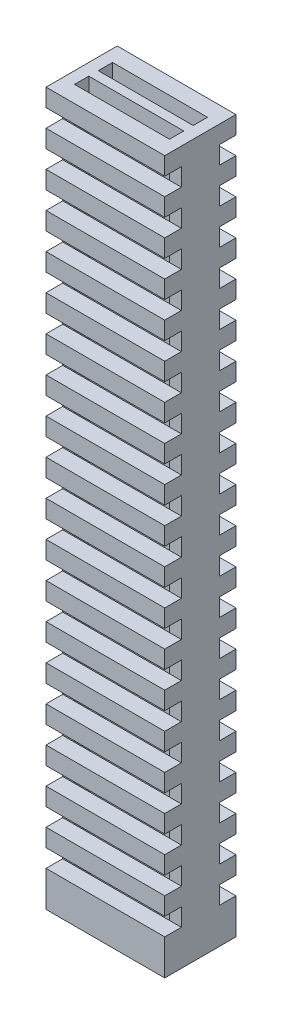
from build123d import *

# Parameters (mm, degrees)
SKETCH1_W                = 5
SKETCH1_H                = 3
BOSS_EXTRUDE1_DEPTH      = 15
CUT_EXTRUDE1_START       = -31
SKETCH2_W                = 4
SKETCH2_H                = 0.6
CUT_EXTRUDE1_DEPTH       = 32
SKETCH3_W                = 5
SKETCH3_H                = 0.75
CUT_EXTRUDE2_DEPTH       = 0.7
LPATTERN1_COUNT          = 19
LPATTERN1_PITCH          = 1.5
MIRROR2_COPY_1_SKETCH_W  = 5
MIRROR2_COPY_1_SKETCH_H  = 0.75
MIRROR2_COPY_1_DEPTH     = 0.7
MIRROR2_COPY_2_SKETCH_W  = 5
MIRROR2_COPY_2_SKETCH_H  = 0.75
MIRROR2_COPY_2_DEPTH     = 0.7
MIRROR2_COPY_3_SKETCH_W  = 5
MIRROR2_COPY_3_SKETCH_H  = 0.75
MIRROR2_COPY_3_DEPTH     = 0.7
MIRROR2_COPY_4_SKETCH_W  = 5
MIRROR2_COPY_4_SKETCH_H  = 0.75
MIRROR2_COPY_4_DEPTH     = 0.7
MIRROR2_COPY_5_SKETCH_W  = 5
MIRROR2_COPY_5_SKETCH_H  = 0.75
MIRROR2_COPY_5_DEPTH     = 0.7
MIRROR2_COPY_6_SKETCH_W  = 5
MIRROR2_COPY_6_SKETCH_H  = 0.75
MIRROR2_COPY_6_DEPTH     = 0.7
MIRROR2_COPY_7_SKETCH_W  = 5
MIRROR2_COPY_7_SKETCH_H  = 0.75
MIRROR2_COPY_7_DEPTH     = 0.7
MIRROR2_COPY_8_SKETCH_W  = 5
MIRROR2_COPY_8_SKETCH_H  = 0.75
MIRROR2_COPY_8_DEPTH     = 0.7
MIRROR2_COPY_9_SKETCH_W  = 5
MIRROR2_COPY_9_SKETCH_H  = 0.75
MIRROR2_COPY_9_DEPTH     = 0.7
MIRROR2_COPY_10_SKETCH_W = 5
MIRROR2_COPY_10_SKETCH_H = 0.75
MIRROR2_COPY_10_DEPTH    = 0.7
MIRROR2_COPY_11_SKETCH_W = 5
MIRROR2_COPY_11_SKETCH_H = 0.75
MIRROR2_COPY_11_DEPTH    = 0.7
MIRROR2_COPY_12_SKETCH_W = 5
MIRROR2_COPY_12_SKETCH_H = 0.75
MIRROR2_COPY_12_DEPTH    = 0.7
MIRROR2_COPY_13_SKETCH_W = 5
MIRROR2_COPY_13_SKETCH_H = 0.75
MIRROR2_COPY_13_DEPTH    = 0.7
MIRROR2_COPY_14_SKETCH_W = 5
MIRROR2_COPY_14_SKETCH_H = 0.75
MIRROR2_COPY_14_DEPTH    = 0.7
MIRROR2_COPY_15_SKETCH_W = 5
MIRROR2_COPY_15_SKETCH_H = 0.75
MIRROR2_COPY_15_DEPTH    = 0.7
MIRROR2_COPY_16_SKETCH_W = 5
MIRROR2_COPY_16_SKETCH_H = 0.75
MIRROR2_COPY_16_DEPTH    = 0.7
MIRROR2_COPY_17_SKETCH_W = 5
MIRROR2_COPY_17_SKETCH_H = 0.75
MIRROR2_COPY_17_DEPTH    = 0.7
MIRROR2_COPY_18_SKETCH_W = 5
MIRROR2_COPY_18_SKETCH_H = 0.75
MIRROR2_COPY_18_DEPTH    = 0.7


with BuildPart() as part:
    # Sketch1 → Boss-Extrude1 (new body, symmetric)
    with BuildSketch(Plane(origin=(0, 0, 0), x_dir=(1, 0, 0), z_dir=(0, 1, 0))):
        Rectangle(SKETCH1_W, SKETCH1_H)
    extrude(amount=BOSS_EXTRUDE1_DEPTH, both=True)

    # Sketch2 → Cut-Extrude1 (cut)
    with BuildSketch(Plane(origin=(0, 15, 0), x_dir=(1, 0, 0), z_dir=(0, 1, 0)).offset(CUT_EXTRUDE1_START)):
        with Locations((0, 0.5)):
            Rectangle(SKETCH2_W, SKETCH2_H)
    cut_extrude1 = extrude(amount=CUT_EXTRUDE1_DEPTH, mode=Mode.SUBTRACT)

    # Mirror1: Cut-Extrude1 across plane
    add(cut_extrude1.mirror(Plane.XY), mode=Mode.SUBTRACT)

    # Sketch3 → Cut-Extrude2 (cut)
    with BuildSketch(Plane.XY.offset(1.5)):
        with Locations((0, 13.875)):
            Rectangle(SKETCH3_W, SKETCH3_H)
    cut_extrude2 = extrude(amount=-CUT_EXTRUDE2_DEPTH, mode=Mode.SUBTRACT)

    # LPattern1: Cut-Extrude2 ×19
    with Locations(*[(0, -i * LPATTERN1_PITCH, 0) for i in range(1, LPATTERN1_COUNT)]):
        add(cut_extrude2, mode=Mode.SUBTRACT)

    # Mirror2: Cut-Extrude2 across plane
    add(cut_extrude2.mirror(Plane.XY), mode=Mode.SUBTRACT)

    # Mirror2 copy 1 sketch → Mirror2 copy 1 (cut)
    with BuildSketch(Plane(origin=(0, -1.5, -1.5), x_dir=(1, 0, 0), z_dir=(0, 0, -1))):
        with Locations((0, -13.875)):
            Rectangle(MIRROR2_COPY_1_SKETCH_W, MIRROR2_COPY_1_SKETCH_H)
    extrude(amount=-MIRROR2_COPY_1_DEPTH, mode=Mode.SUBTRACT)

    # Mirror2 copy 2 sketch → Mirror2 copy 2 (cut)
    with BuildSketch(Plane(origin=(0, -3, -1.5), x_dir=(1, 0, 0), z_dir=(0, 0, -1))):
        with Locations((0, -13.875)):
            Rectangle(MIRROR2_COPY_2_SKETCH_W, MIRROR2_COPY_2_SKETCH_H)
    extrude(amount=-MIRROR2_COPY_2_DEPTH, mode=Mode.SUBTRACT)

    # Mirror2 copy 3 sketch → Mirror2 copy 3 (cut)
    with BuildSketch(Plane(origin=(0, -4.5, -1.5), x_dir=(1, 0, 0), z_dir=(0, 0, -1))):
        with Locations((0, -13.875)):
            Rectangle(MIRROR2_COPY_3_SKETCH_W, MIRROR2_COPY_3_SKETCH_H)
    extrude(amount=-MIRROR2_COPY_3_DEPTH, mode=Mode.SUBTRACT)

    # Mirror2 copy 4 sketch → Mirror2 copy 4 (cut)
    with BuildSketch(Plane(origin=(0, -6, -1.5), x_dir=(1, 0, 0), z_dir=(0, 0, -1))):
        with Locations((0, -13.875)):
            Rectangle(MIRROR2_COPY_4_SKETCH_W, MIRROR2_COPY_4_SKETCH_H)
    extrude(amount=-MIRROR2_COPY_4_DEPTH, mode=Mode.SUBTRACT)

    # Mirror2 copy 5 sketch → Mirror2 copy 5 (cut)
    with BuildSketch(Plane(origin=(0, -7.5, -1.5), x_dir=(1, 0, 0), z_dir=(0, 0, -1))):
        with Locations((0, -13.875)):
            Rectangle(MIRROR2_COPY_5_SKETCH_W, MIRROR2_COPY_5_SKETCH_H)
    extrude(amount=-MIRROR2_COPY_5_DEPTH, mode=Mode.SUBTRACT)

    # Mirror2 copy 6 sketch → Mirror2 copy 6 (cut)
    with BuildSketch(Plane(origin=(0, -9, -1.5), x_dir=(1, 0, 0), z_dir=(0, 0, -1))):
        with Locations((0, -13.875)):
            Rectangle(MIRROR2_COPY_6_SKETCH_W, MIRROR2_COPY_6_SKETCH_H)
    extrude(amount=-MIRROR2_COPY_6_DEPTH, mode=Mode.SUBTRACT)

    # Mirror2 copy 7 sketch → Mirror2 copy 7 (cut)
    with BuildSketch(Plane(origin=(0, -10.5, -1.5), x_dir=(1, 0, 0), z_dir=(0, 0, -1))):
        with Locations((0, -13.875)):
            Rectangle(MIRROR2_COPY_7_SKETCH_W, MIRROR2_COPY_7_SKETCH_H)
    extrude(amount=-MIRROR2_COPY_7_DEPTH, mode=Mode.SUBTRACT)

    # Mirror2 copy 8 sketch → Mirror2 copy 8 (cut)
    with BuildSketch(Plane(origin=(0, -12, -1.5), x_dir=(1, 0, 0), z_dir=(0, 0, -1))):
        with Locations((0, -13.875)):
            Rectangle(MIRROR2_COPY_8_SKETCH_W, MIRROR2_COPY_8_SKETCH_H)
    extrude(amount=-MIRROR2_COPY_8_DEPTH, mode=Mode.SUBTRACT)

    # Mirror2 copy 9 sketch → Mirror2 copy 9 (cut)
    with BuildSketch(Plane(origin=(0, -13.5, -1.5), x_dir=(1, 0, 0), z_dir=(0, 0, -1))):
        with Locations((0, -13.875)):
            Rectangle(MIRROR2_COPY_9_SKETCH_W, MIRROR2_COPY_9_SKETCH_H)
    extrude(amount=-MIRROR2_COPY_9_DEPTH, mode=Mode.SUBTRACT)

    # Mirror2 copy 10 sketch → Mirror2 copy 10 (cut)
    with BuildSketch(Plane(origin=(0, -15, -1.5), x_dir=(1, 0, 0), z_dir=(0, 0, -1))):
        with Locations((0, -13.875)):
            Rectangle(MIRROR2_COPY_10_SKETCH_W, MIRROR2_COPY_10_SKETCH_H)
    extrude(amount=-MIRROR2_COPY_10_DEPTH, mode=Mode.SUBTRACT)

    # Mirror2 copy 11 sketch → Mirror2 copy 11 (cut)
    with BuildSketch(Plane(origin=(0, -16.5, -1.5), x_dir=(1, 0, 0), z_dir=(0, 0, -1))):
        with Locations((0, -13.875)):
            Rectangle(MIRROR2_COPY_11_SKETCH_W, MIRROR2_COPY_11_SKETCH_H)
    extrude(amount=-MIRROR2_COPY_11_DEPTH, mode=Mode.SUBTRACT)

    # Mirror2 copy 12 sketch → Mirror2 copy 12 (cut)
    with BuildSketch(Plane(origin=(0, -18, -1.5), x_dir=(1, 0, 0), z_dir=(0, 0, -1))):
        with Locations((0, -13.875)):
            Rectangle(MIRROR2_COPY_12_SKETCH_W, MIRROR2_COPY_12_SKETCH_H)
    extrude(amount=-MIRROR2_COPY_12_DEPTH, mode=Mode.SUBTRACT)

    # Mirror2 copy 13 sketch → Mirror2 copy 13 (cut)
    with BuildSketch(Plane(origin=(0, -19.5, -1.5), x_dir=(1, 0, 0), z_dir=(0, 0, -1))):
        with Locations((0, -13.875)):
            Rectangle(MIRROR2_COPY_13_SKETCH_W, MIRROR2_COPY_13_SKETCH_H)
    extrude(amount=-MIRROR2_COPY_13_DEPTH, mode=Mode.SUBTRACT)

    # Mirror2 copy 14 sketch → Mirror2 copy 14 (cut)
    with BuildSketch(Plane(origin=(0, -21, -1.5), x_dir=(1, 0, 0), z_dir=(0, 0, -1))):
        with Locations((0, -13.875)):
            Rectangle(MIRROR2_COPY_14_SKETCH_W, MIRROR2_COPY_14_SKETCH_H)
    extrude(amount=-MIRROR2_COPY_14_DEPTH, mode=Mode.SUBTRACT)

    # Mirror2 copy 15 sketch → Mirror2 copy 15 (cut)
    with BuildSketch(Plane(origin=(0, -22.5, -1.5), x_dir=(1, 0, 0), z_dir=(0, 0, -1))):
        with Locations((0, -13.875)):
            Rectangle(MIRROR2_COPY_15_SKETCH_W, MIRROR2_COPY_15_SKETCH_H)
    extrude(amount=-MIRROR2_COPY_15_DEPTH, mode=Mode.SUBTRACT)

    # Mirror2 copy 16 sketch → Mirror2 copy 16 (cut)
    with BuildSketch(Plane(origin=(0, -24, -1.5), x_dir=(1, 0, 0), z_dir=(0, 0, -1))):
        with Locations((0, -13.875)):
            Rectangle(MIRROR2_COPY_16_SKETCH_W, MIRROR2_COPY_16_SKETCH_H)
    extrude(amount=-MIRROR2_COPY_16_DEPTH, mode=Mode.SUBTRACT)

    # Mirror2 copy 17 sketch → Mirror2 copy 17 (cut)
    with BuildSketch(Plane(origin=(0, -25.5, -1.5), x_dir=(1, 0, 0), z_dir=(0, 0, -1))):
        with Locations((0, -13.875)):
            Rectangle(MIRROR2_COPY_17_SKETCH_W, MIRROR2_COPY_17_SKETCH_H)
    extrude(amount=-MIRROR2_COPY_17_DEPTH, mode=Mode.SUBTRACT)

    # Mirror2 copy 18 sketch → Mirror2 copy 18 (cut)
    with BuildSketch(Plane(origin=(0, -27, -1.5), x_dir=(1, 0, 0), z_dir=(0, 0, -1))):
        with Locations((0, -13.875)):
            Rectangle(MIRROR2_COPY_18_SKETCH_W, MIRROR2_COPY_18_SKETCH_H)
    extrude(amount=-MIRROR2_COPY_18_DEPTH, mode=Mode.SUBTRACT)


solid = part.part
